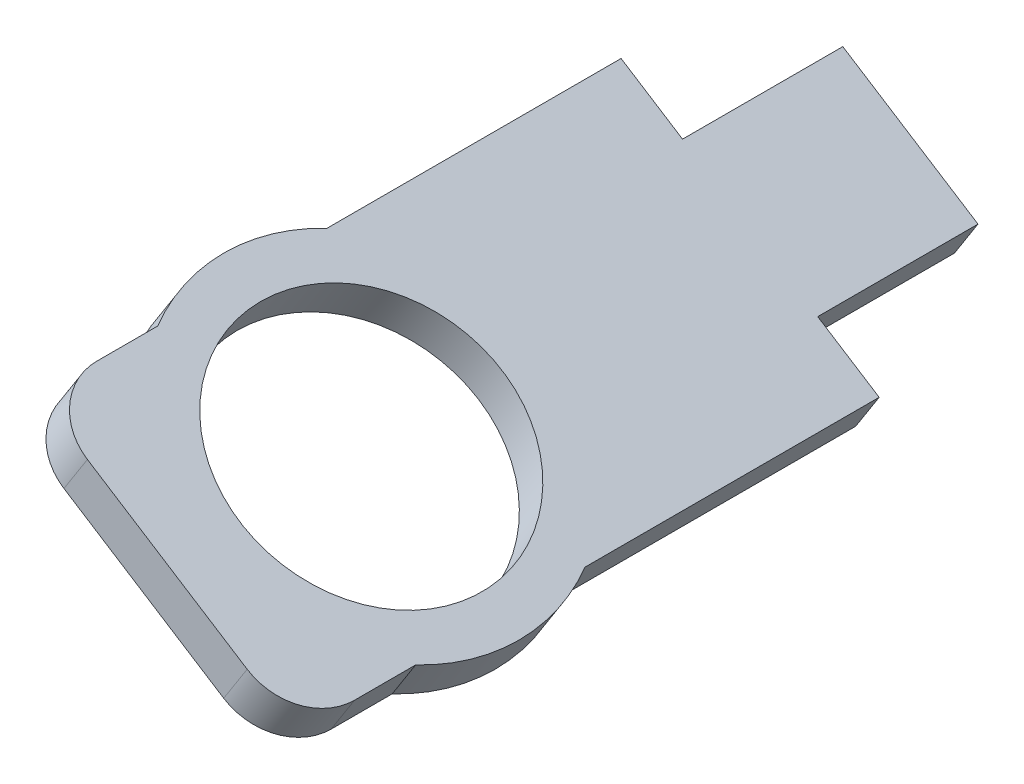
from build123d import *

# Parameters (mm, degrees)
SALIENTE_EXTRUIR1_DEPTH = 11
SALIENTE_EXTRUIR2_DEPTH = 40
CROQUIS3_R              = 12
CROQUIS3_R_2            = 9
SALIENTE_EXTRUIR3_DEPTH = 3
CROQUIS3_2_R            = 9
CORTAR_EXTRUIR1_DEPTH   = 10
REDONDEO1_R             = 4


with BuildPart() as part:
    # Croquis1 → Saliente-Extruir1 (new body)
    with BuildSketch(Plane.XY):
        Polygon((-32.04318068, 26.167112062), (-30.431281855, 28.697286399), (-39.708587759, 34.607582091), (-41.320486584, 32.077407754), align=None)
    extrude(amount=-SALIENTE_EXTRUIR1_DEPTH)

    # Croquis2 → Saliente-Extruir2 (add)
    with BuildSketch(Plane.XY):
        Polygon((-26.214324626, 26.010788357), (-43.925544988, 37.294080133), (-45.537443813, 34.763905795), (-32.04318068, 26.167112062), (-27.826223451, 23.48061402), align=None)
    extrude(amount=SALIENTE_EXTRUIR2_DEPTH)

    # Croquis3 → Saliente-Extruir3 (add)
    with BuildSketch(Plane(origin=(4.219053857, 6.622587989, 0), x_dir=(0.843391446, -0.537299608, 0), z_dir=(0.537299608, 0.843391446, 0))):
        with Locations((-46.584523545, -26)):
            Circle(CROQUIS3_R)
        with Locations((-46.584523545, -26)):
            Circle(CROQUIS3_R_2, mode=Mode.SUBTRACT)
    extrude(amount=-SALIENTE_EXTRUIR3_DEPTH)

    # Croquis3_2 → Cortar-Extruir1 (cut)
    with BuildSketch(Plane(origin=(4.219053857, 6.622587989, 0), x_dir=(0.843391446, -0.537299608, 0), z_dir=(0.537299608, 0.843391446, 0))):
        with Locations((-46.584523545, -26)):
            Circle(CROQUIS3_2_R)
    extrude(amount=-CORTAR_EXTRUIR1_DEPTH, mode=Mode.SUBTRACT)

    # Redondeo1
    redondeo1_edges = [part.edges().sort_by_distance(p)[0] for p in [
        (-27.020274039, 24.745701189, 40),
        (-44.731494401, 36.028992964, 40),
    ]]
    fillet(redondeo1_edges, radius=REDONDEO1_R)


solid = part.part
